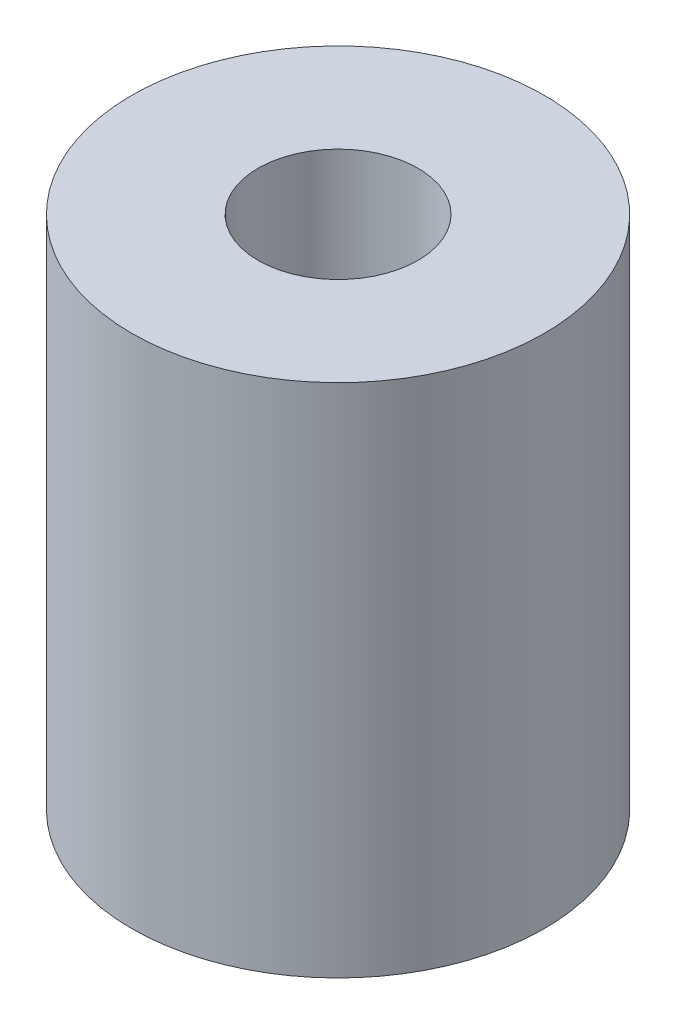
from build123d import *

# Parameters (mm, degrees)
SKETCH1_R           = 8
BOSS_EXTRUDE1_DEPTH = 20
CUT_EXTRUDE1_REACH  = 22
SKETCH2_R           = 3.1


with BuildPart() as part:
    # Sketch1 → Boss-Extrude1 (new body)
    with BuildSketch(Plane(origin=(0, 0, 0), x_dir=(1, 0, 0), z_dir=(0, 1, 0))):
        Circle(SKETCH1_R)
    extrude(amount=BOSS_EXTRUDE1_DEPTH)

    # Sketch2 → Cut-Extrude1 (cut, up to next)
    with BuildSketch(Plane(origin=(0, 20, 0), x_dir=(1, 0, 0), z_dir=(0, 1, 0)), mode=Mode.PRIVATE) as cut_extrude1_sk1:
        Circle(SKETCH2_R)
    cut_extrude1_tool1 = extrude(cut_extrude1_sk1.sketch, amount=-CUT_EXTRUDE1_REACH, mode=Mode.PRIVATE) & part.part
    add(cut_extrude1_tool1.solids().sort_by_distance((0, 20, 0))[0], mode=Mode.SUBTRACT)


solid = part.part
